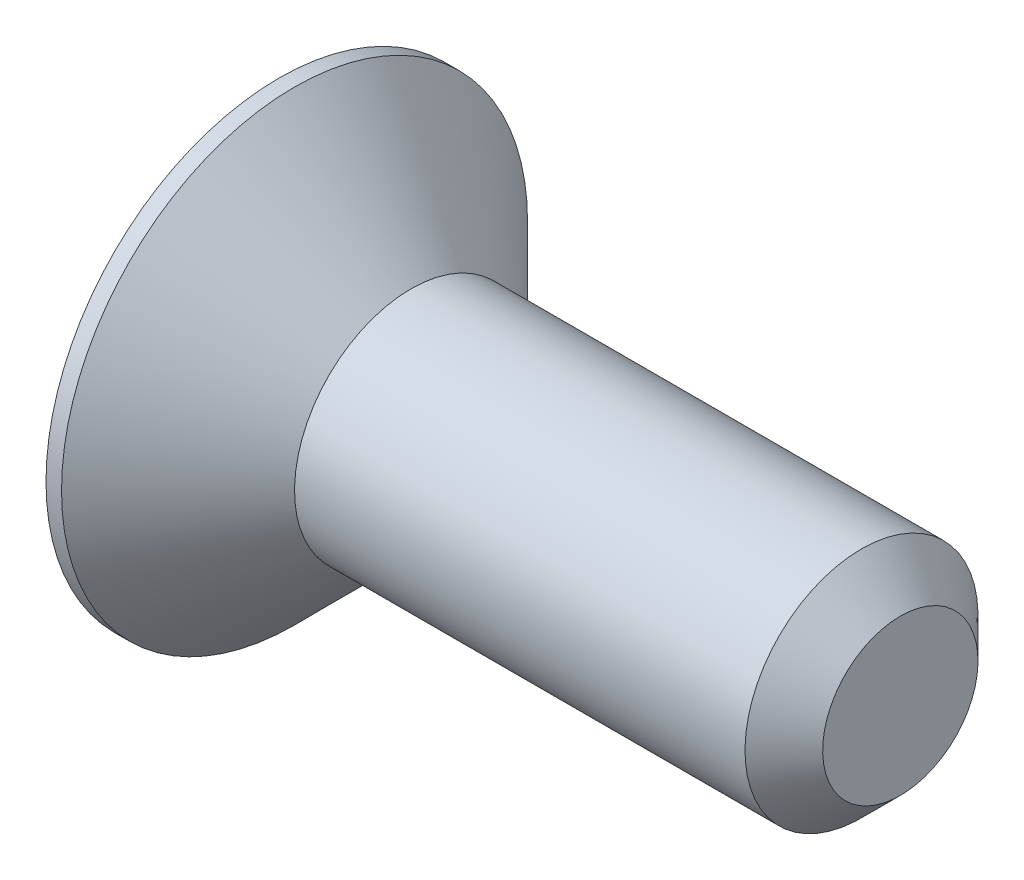
from build123d import *

# Parameters (mm, degrees)
CHANFREIN1_SIZE         = 0.5
ENL_V_MAT_EXTRU_1_DEPTH = 1.2


with BuildPart() as part:
    # Esquisse1 → Révolution1 (revolve)
    with BuildSketch(Plane.XY):
        Polygon((0, 0), (0, 3), (0.2, 3), (1.7, 1.5), (8, 1.5), (8, 0), align=None)
    revolve(axis=Axis((8, 0, 0), (-1, 0, 0)))

    # Chanfrein1
    chanfrein1_edges = [part.edges().sort_by_distance(p)[0] for p in [
        (8, -1.5, 0),
    ]]
    chamfer(chanfrein1_edges, length=CHANFREIN1_SIZE)

    # Esquisse2 → Enlèv. mat.-Extru.1 (cut)
    with BuildSketch(Plane.ZY):
        Polygon((0, 1.154700538), (-1, 0.577350269), (-1, -0.577350269), (0, -1.154700538), (1, -0.577350269), (1, 0.577350269), align=None)
    extrude(amount=-ENL_V_MAT_EXTRU_1_DEPTH, mode=Mode.SUBTRACT)


solid = part.part
